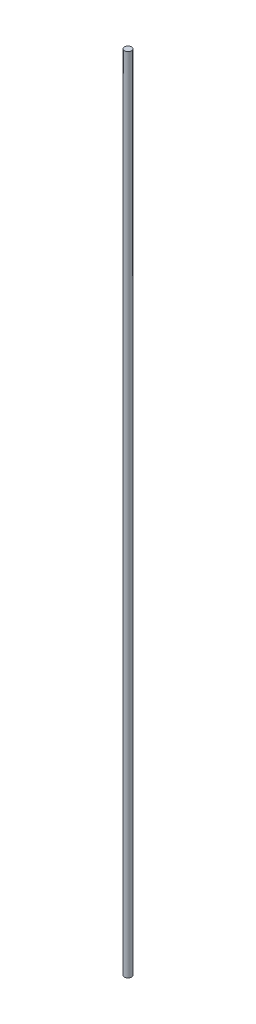
from build123d import *

# Parameters (mm, degrees)
SKETCH_1_R      = 4
EXTRUDE_1_DEPTH = 915


with BuildPart() as part:
    # Эскиз1 → Бобышка-Вытянуть1 (new body)
    with BuildSketch(Plane(origin=(0, 0, 0), x_dir=(1, 0, 0), z_dir=(0, 1, 0))):
        Circle(SKETCH_1_R)
    extrude(amount=EXTRUDE_1_DEPTH)


solid = part.part
